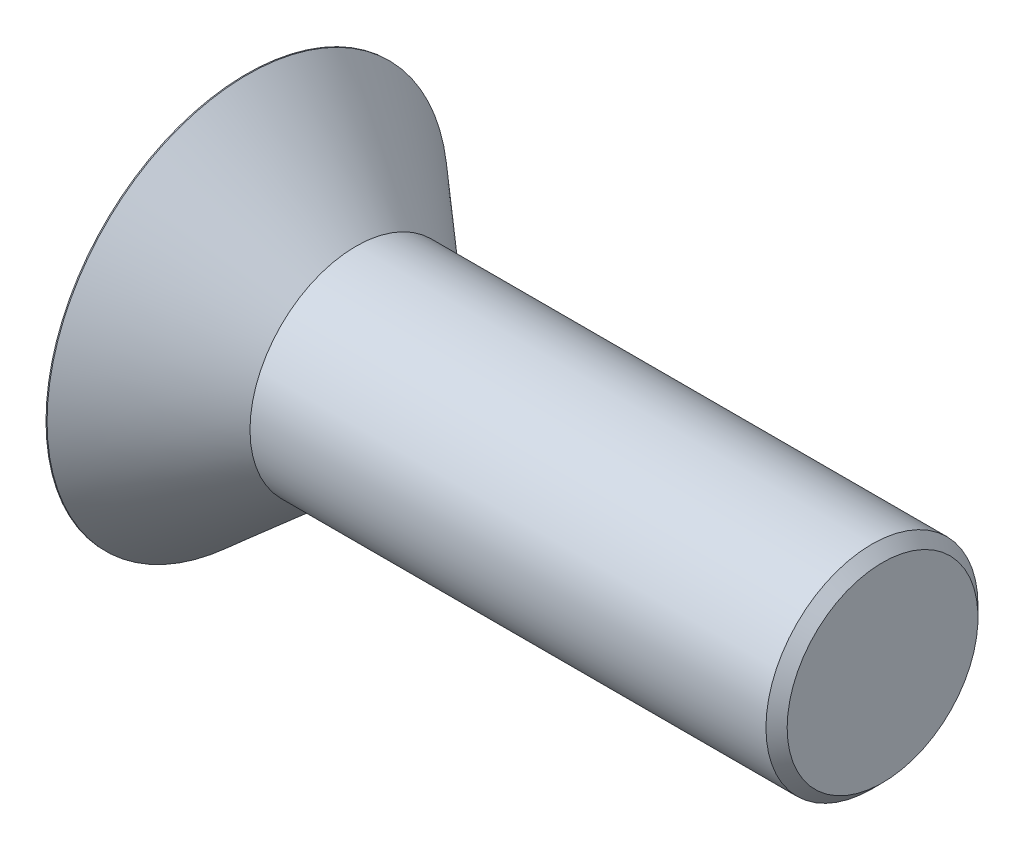
from build123d import *

# Parameters (mm, degrees)
HEX_2_DEPTH = 7.5438


with BuildPart() as part:
    # BodySke → BaseBody (revolve)
    with BuildSketch(Plane.XY, mode=Mode.PRIVATE) as basebody_sk:
        Polygon((0, 0), (0, 24.003), (0.127, 24.003), (13.129614107, 12.7), (74.93, 12.7), (76.2, 11.43), (76.2, 0), align=None)
    revolve(basebody_sk.sketch.rotate(Axis((0, 0, 0), (1, 0, 0)), 90), axis=Axis((0, 0, 0), (1, 0, 0)))  # turned: the seam where the file's is

    # Sketch2 → PreBroach (revolve, cut)
    with BuildSketch(Plane.XY, mode=Mode.PRIVATE) as prebroach_sk:
        Polygon((0, 7.9375), (7.5438, 7.9375), (12.126517762, 0), (0, 0), align=None)
    revolve(prebroach_sk.sketch.rotate(Axis((0, 0, 0), (1, 0, 0)), 90), axis=Axis((0, 0, 0), (1, 0, 0)), mode=Mode.SUBTRACT)  # turned: the seam where the file's is

    # Sketch3 → Hex 2 (cut)
    with BuildSketch(Plane.ZY):
        Polygon((-7.9375, -4.582717762), (-7.9375, 4.582717762), (0, 9.165435523), (7.9375, 4.582717762), (7.9375, -4.582717762), (0, -9.165435523), align=None)
    extrude(amount=-HEX_2_DEPTH, mode=Mode.SUBTRACT)


solid = part.part
